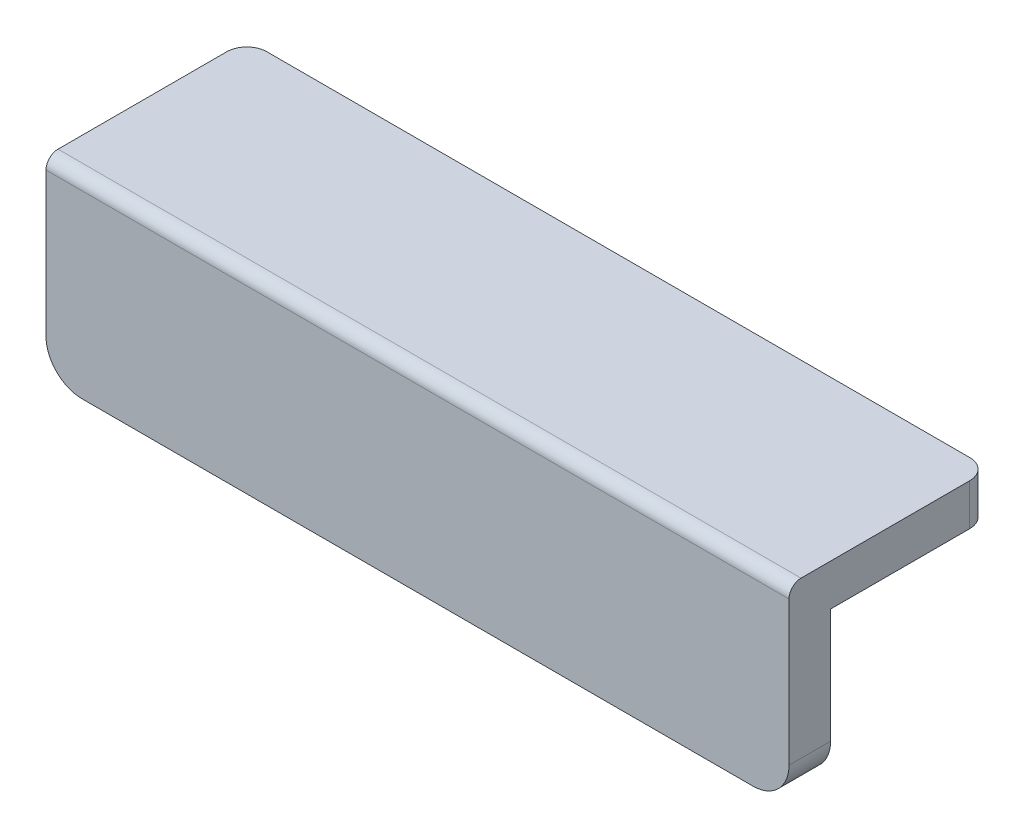
from build123d import *

# Parameters (mm, degrees)
SKETCH1_W           = 93.98
SKETCH1_H           = 19.05
BOSS_EXTRUDE1_DEPTH = 2.6289
SKETCH2_W           = 93.98
SKETCH2_H           = 25.4
BOSS_EXTRUDE2_DEPTH = 5.2578
FILLET6_R           = 4.572
FILLET7_R           = 4.572
FILLET8_R           = 1.524
FILLET9_R           = 2.54
FILLET10_R          = 2.54


with BuildPart() as part:
    # Sketch1 → Boss-Extrude1 (new body, symmetric)
    with BuildSketch(Plane.XY):
        Rectangle(SKETCH1_W, SKETCH1_H)
    extrude(amount=BOSS_EXTRUDE1_DEPTH, both=True)

    # Sketch2 → Boss-Extrude2 (add)
    with BuildSketch(Plane(origin=(0, 9.525, 0), x_dir=(1, 0, 0), z_dir=(0, 1, 0))):
        with Locations((0, 10.0711)):
            Rectangle(SKETCH2_W, SKETCH2_H)
    extrude(amount=BOSS_EXTRUDE2_DEPTH)

    # Fillet6
    fillet6_edges = [part.edges().sort_by_distance(p)[0] for p in [
        (-46.99, -9.525, 0),
    ]]
    fillet(fillet6_edges, radius=FILLET6_R)

    # Fillet7
    fillet7_edges = [part.edges().sort_by_distance(p)[0] for p in [
        (46.99, -9.525, 0),
    ]]
    fillet(fillet7_edges, radius=FILLET7_R)

    # Fillet8
    fillet8_edges = [part.edges().sort_by_distance(p)[0] for p in [
        (0, 14.7828, 2.6289),
    ]]
    fillet(fillet8_edges, radius=FILLET8_R)

    # Fillet9
    fillet9_edges = [part.edges().sort_by_distance(p)[0] for p in [
        (-46.99, 12.1539, -22.7711),
    ]]
    fillet(fillet9_edges, radius=FILLET9_R)

    # Fillet10
    fillet10_edges = [part.edges().sort_by_distance(p)[0] for p in [
        (46.99, 12.1539, -22.7711),
    ]]
    fillet(fillet10_edges, radius=FILLET10_R)


solid = part.part
